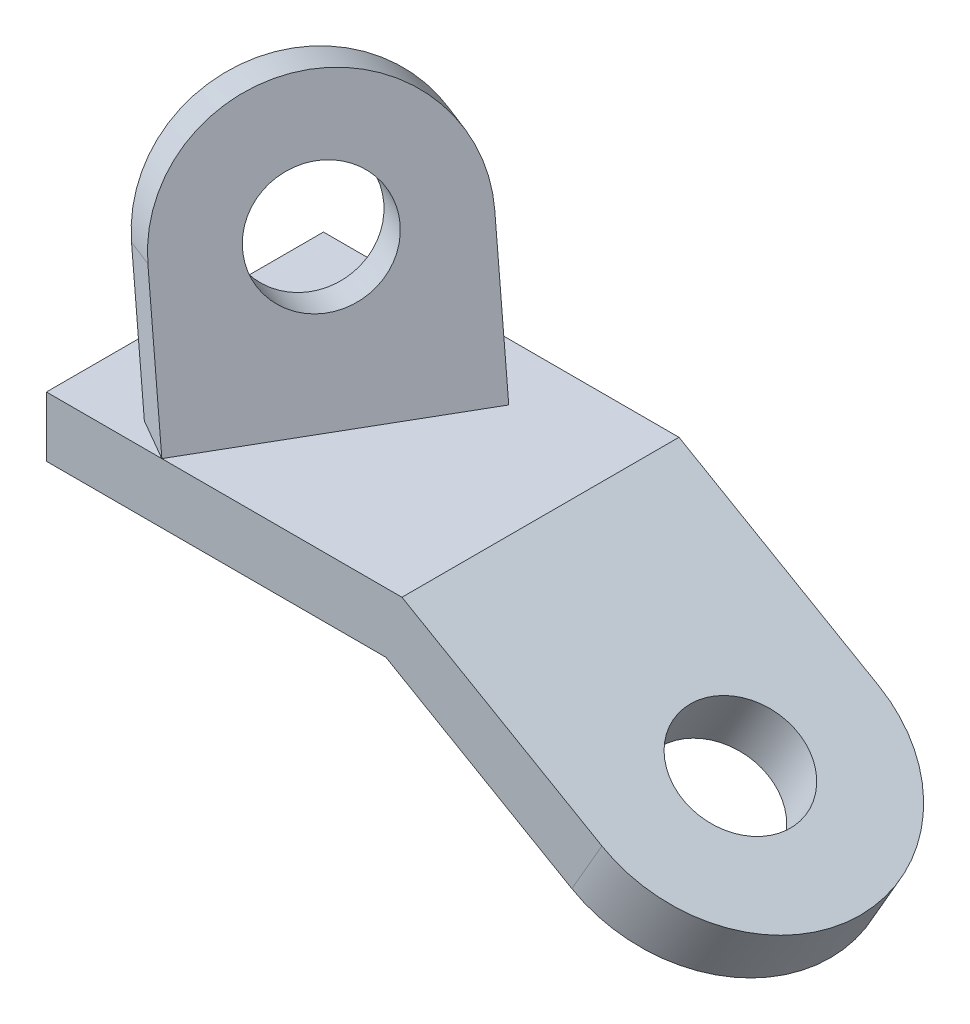
from build123d import *

# Parameters (mm, degrees)
BOSS_EXTRUDE1_DEPTH = 60
CUT_EXTRUDE1_DEPTH  = 60
SKETCH3_R           = 12.5
CUT_EXTRUDE2_DEPTH  = 60
BOSS_EXTRUDE2_DEPTH = 10
SKETCH6_R           = 12.5
CUT_EXTRUDE3_DEPTH  = 59


with BuildPart() as part:
    # Sketch1 → Boss-Extrude1 (new body)
    with BuildSketch(Plane.XY):
        Polygon((0, 0), (0, 13), (77, 13), (146.282032303, -27), (139.782032303, -38.258330249), (73.516660498, 0), align=None)
    extrude(amount=-BOSS_EXTRUDE1_DEPTH)

    # Sketch2 → Cut-Extrude1 (cut)
    with BuildSketch(Plane(origin=(24.879165125, 43.091978046, 0), x_dir=(0.866025404, -0.5, 0), z_dir=(0.5, 0.866025404, 0))):
        with BuildLine():
            Line((140.183956091, 60), (110.183956091, 60))
            ThreePointArc((110.183956091, 60), (131.397159527, 51.213203436), (140.183956091, 30))
            Line((140.183956091, 30), (140.183956091, 60))
        make_face()
        with BuildLine():
            ThreePointArc((140.183956091, 30), (131.397159527, 8.786796564), (110.183956091, 0))
            Line((110.183956091, 0), (140.183956091, 0))
            Line((140.183956091, 0), (140.183956091, 30))
        make_face()
    extrude(amount=-CUT_EXTRUDE1_DEPTH, mode=Mode.SUBTRACT)

    # Sketch3 → Cut-Extrude2 (cut)
    with BuildSketch(Plane(origin=(24.879165125, 43.091978046, 0), x_dir=(0.866025404, -0.5, 0), z_dir=(0.5, 0.866025404, 0))):
        with Locations((110.183956091, 30)):
            Circle(SKETCH3_R)
    extrude(amount=-CUT_EXTRUDE2_DEPTH, mode=Mode.SUBTRACT)

    # Sketch5 → Boss-Extrude2 (add)
    with BuildSketch(Plane(origin=(20.308570723, 6.283493649, 11.725158774), x_dir=(0.5, 0, -0.866025404), z_dir=(0.836516304, 0.258819045, 0.482962913))):
        with BuildLine():
            Line((12.5, 6.953439041), (67.5, 6.953439041))
            Line((67.5, 6.953439041), (67.5, 38.953439041))
            ThreePointArc((67.5, 38.953439041), (40, 66.453439041), (12.5, 38.953439041))
            Line((12.5, 38.953439041), (12.5, 6.953439041))
        make_face()
    extrude(amount=-BOSS_EXTRUDE2_DEPTH)

    # Sketch6 → Cut-Extrude3 (cut)
    with BuildSketch(Plane(origin=(20.308570723, 6.283493649, 11.725158774), x_dir=(0.461383649, 0.142752598, -0.875640808), z_dir=(0.836516304, 0.258819045, 0.482962913))):
        with Locations((45.317625377, 32.614157099)):
            Circle(SKETCH6_R)
    extrude(amount=-CUT_EXTRUDE3_DEPTH, mode=Mode.SUBTRACT)


solid = part.part
